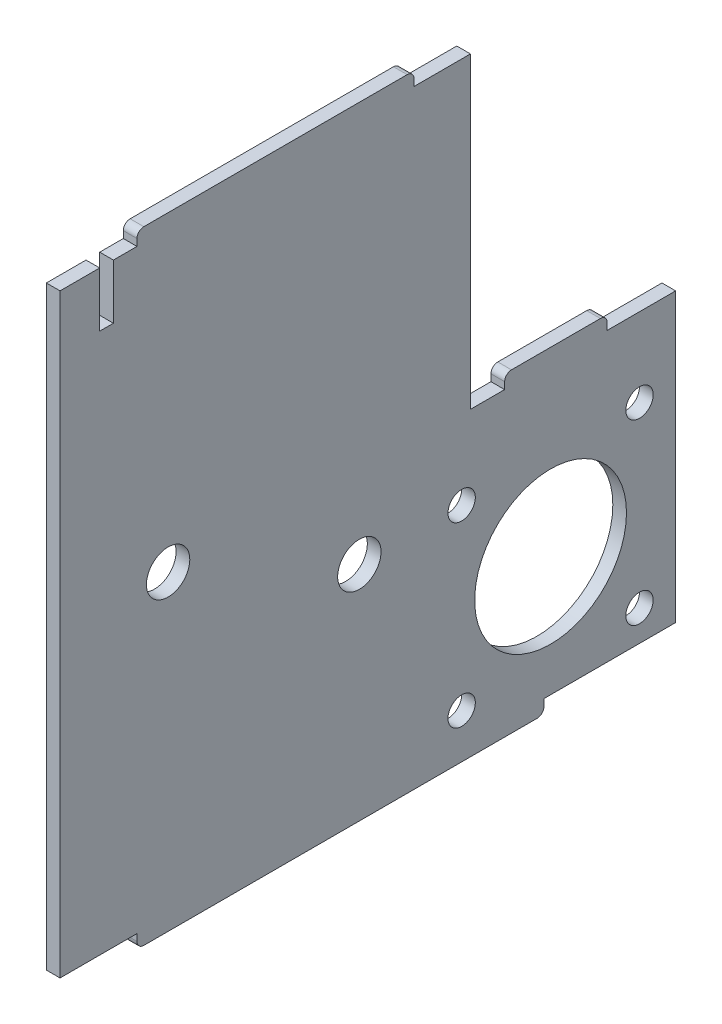
from build123d import *

# Parameters (mm, degrees)
SKETCH1_R           = 3.17
SKETCH1_R_2         = 11.1
SKETCH1_R_3         = 2
BOSS_EXTRUDE2_DEPTH = 2


with BuildPart() as part:
    # Sketch1 → Boss-Extrude2 (new body)
    with BuildSketch(Plane(origin=(0, 0, 0), x_dir=(0, 0, -1), z_dir=(1, 0, 0))):
        with BuildLine():
            Line((47.801233781, -63.131130768), (47.801233781, -21.131130768))
            Line((47.801233781, -21.131130768), (37.801233781, -21.131130768))
            Line((37.801233781, -21.131130768), (37.801233781, -20.131130768))
            ThreePointArc((37.801233781, -20.131130768), (37.508340562, -19.424023986), (36.801233781, -19.131130768))
            Line((36.801233781, -19.131130768), (23.801233781, -19.131130768))
            ThreePointArc((23.801233781, -19.131130768), (23.094127, -19.424023986), (22.801233781, -20.131130768))
            Line((22.801233781, -20.131130768), (22.801233781, -21.131130768))
            Line((22.801233781, -21.131130768), (17.801233781, -21.131130768))
            Line((17.801233781, -21.131130768), (17.801233781, 23.868869232))
            Line((17.801233781, 23.868869232), (9.55072491, 23.868869232))
            Line((9.55072491, 23.868869232), (9.55072491, 24.868869232))
            ThreePointArc((9.55072491, 24.868869232), (9.257831691, 25.575976014), (8.55072491, 25.868869232))
            Line((8.55072491, 25.868869232), (-29.948257347, 25.868869232))
            ThreePointArc((-29.948257347, 25.868869232), (-30.655364129, 25.575976014), (-30.948257347, 24.868869232))
            Line((-30.948257347, 24.868869232), (-30.948257347, 23.868869232))
            Line((-30.948257347, 23.868869232), (-34.398766219, 23.868869232))
            Line((-34.398766219, 23.868869232), (-34.398766219, 15.868869232))
            Line((-34.398766219, 15.868869232), (-36.398766219, 15.868869232))
            Line((-36.398766219, 15.868869232), (-36.398766219, 23.868869232))
            Line((-36.398766219, 23.868869232), (-42.198766219, 23.868869232))
            Line((-42.198766219, 23.868869232), (-42.198766219, -63.131130768))
            Line((-42.198766219, -63.131130768), (-30.948257347, -63.131130768))
            Line((-30.948257347, -63.131130768), (-30.948257347, -64.131130768))
            ThreePointArc((-30.948257347, -64.131130768), (-30.655364129, -64.838237549), (-29.948257347, -65.131130768))
            Line((-29.948257347, -65.131130768), (27.55072491, -65.131130768))
            ThreePointArc((27.55072491, -65.131130768), (28.257831691, -64.838237549), (28.55072491, -64.131130768))
            Line((28.55072491, -64.131130768), (28.55072491, -63.131130768))
            Line((28.55072491, -63.131130768), (47.801233781, -63.131130768))
        make_face()
        with Locations((-26.398766219, -19.631130768)):
            Circle(SKETCH1_R, mode=Mode.SUBTRACT)
        with Locations((29.515713155, -45.631130768)):
            Circle(SKETCH1_R_2, mode=Mode.SUBTRACT)
        with Locations((16.515713155, -32.631130768)):
            Circle(SKETCH1_R_3, mode=Mode.SUBTRACT)
        with Locations((42.515713155, -32.631130768)):
            Circle(SKETCH1_R_3, mode=Mode.SUBTRACT)
        with Locations((42.515713155, -58.631130768)):
            Circle(SKETCH1_R_3, mode=Mode.SUBTRACT)
        with Locations((16.515713155, -58.631130768)):
            Circle(SKETCH1_R_3, mode=Mode.SUBTRACT)
        with Locations((1.558473468, -32.631130768)):
            Circle(SKETCH1_R, mode=Mode.SUBTRACT)
    extrude(amount=BOSS_EXTRUDE2_DEPTH)


solid = part.part
